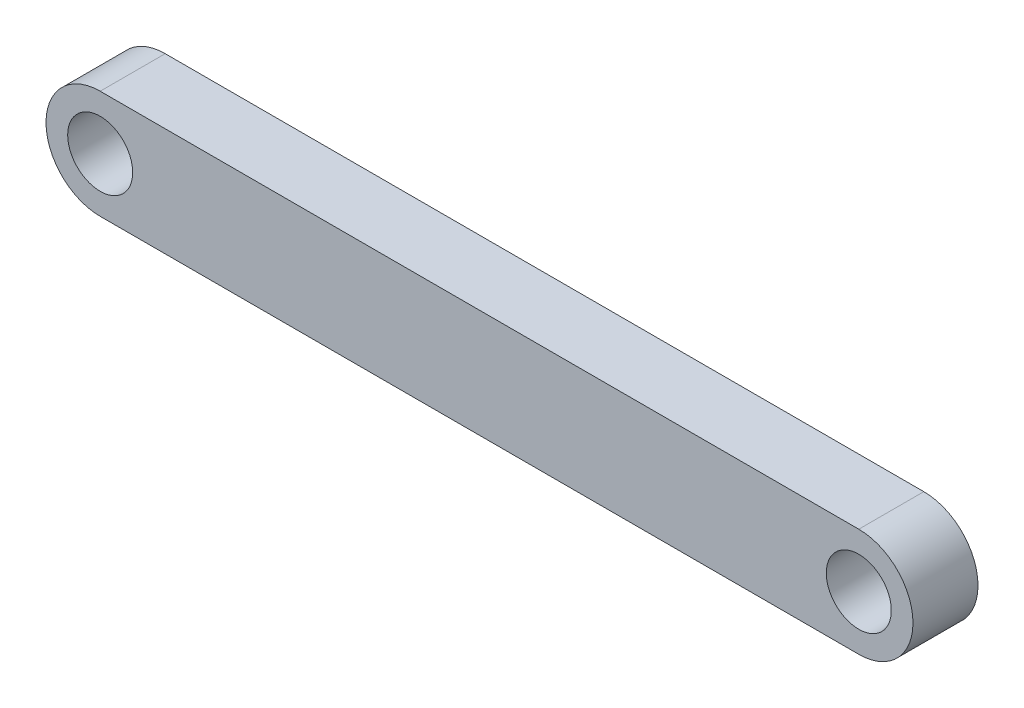
from build123d import *

# Parameters (mm, degrees)
AUFSATZ_LINEAR_START            = 3
SKIZZE2_R                       = 3
AUFSATZ_LINEAR_AUSTRAGEN1_DEPTH = 6


with BuildPart() as part:
    # Skizze2 → Aufsatz-Linear austragen1 (new body)
    with BuildSketch(Plane.XY.offset(AUFSATZ_LINEAR_START)):
        with BuildLine():
            Line((0, 675), (70, 675))
            ThreePointArc((70, 675), (75, 670), (70, 665))
            Line((70, 665), (0, 665))
            ThreePointArc((0, 665), (-5, 670), (0, 675))
        make_face()
        with Locations((0, 670)):
            Circle(SKIZZE2_R, mode=Mode.SUBTRACT)
        with Locations((70, 670)):
            Circle(SKIZZE2_R, mode=Mode.SUBTRACT)
    extrude(amount=AUFSATZ_LINEAR_AUSTRAGEN1_DEPTH)


solid = part.part
